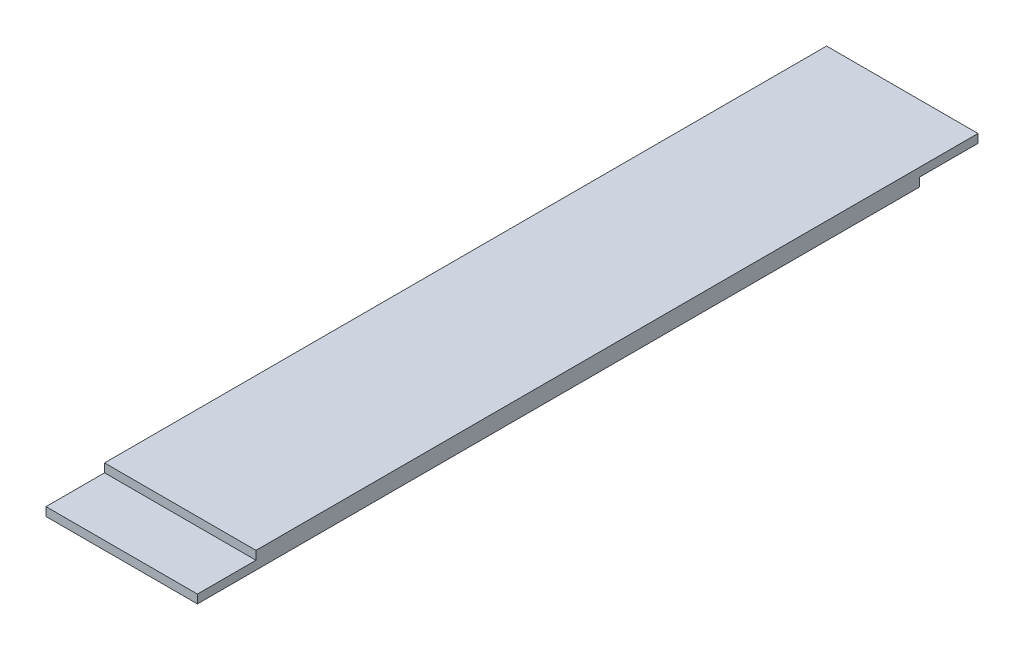
from build123d import *

# Parameters (mm, degrees)
SKETCH_1_W          = 38.8
SKETCH_1_H          = 200
EXTRUDE_1_DEPTH     = 4.4
SKETCH_2_W          = 38.8
SKETCH_2_H          = 15
CUT_EXTRUDE_1_DEPTH = 2.2
SKETCH_3_W          = 38.8
SKETCH_3_H          = 15
CUT_EXTRUDE_2_DEPTH = 2.2


with BuildPart() as part:
    # 草圖1 → 填料-伸長1 (new body)
    with BuildSketch(Plane(origin=(0, 0, 0), x_dir=(1, 0, 0), z_dir=(0, 1, 0))):
        Rectangle(SKETCH_1_W, SKETCH_1_H)
    extrude(amount=EXTRUDE_1_DEPTH)

    # 草圖2 → 除料-伸長1 (cut)
    with BuildSketch(Plane(origin=(0, 4.4, 0), x_dir=(1, 0, 0), z_dir=(0, 1, 0))):
        with Locations((0, -92.5)):
            Rectangle(SKETCH_2_W, SKETCH_2_H)
    extrude(amount=-CUT_EXTRUDE_1_DEPTH, mode=Mode.SUBTRACT)

    # 草圖3 → 除料-伸長2 (cut)
    with BuildSketch(Plane.XZ):
        with Locations((0, -92.5)):
            Rectangle(SKETCH_3_W, SKETCH_3_H)
    extrude(amount=-CUT_EXTRUDE_2_DEPTH, mode=Mode.SUBTRACT)


solid = part.part
